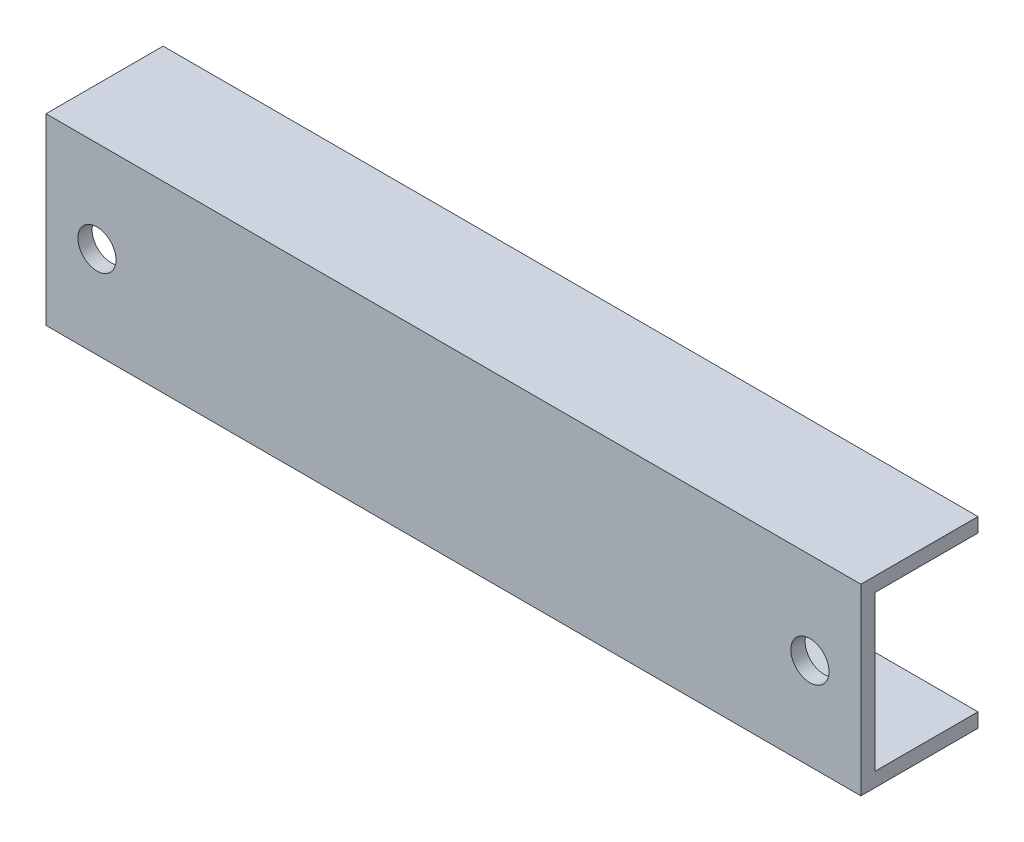
from build123d import *

# Parameters (mm, degrees)
BOSS_EXTRUDE1_DEPTH = 50.8
SKETCH3_R           = 2.38125
CUT_EXTRUDE1_DEPTH  = 15.605


with BuildPart() as part:
    # Sketch1 → Boss-Extrude1 (new body, symmetric)
    with BuildSketch(Plane(origin=(0, 0, 0), x_dir=(0, 0, -1), z_dir=(1, 0, 0))):
        Polygon((0, 11.43), (0, -11.43), (14.605, -11.43), (14.605, -9.652), (1.778, -9.652), (1.778, 9.652), (14.605, 9.652), (14.605, 11.43), align=None)
    extrude(amount=BOSS_EXTRUDE1_DEPTH, both=True)

    # Sketch3 → Cut-Extrude1 (cut, through all)
    with BuildSketch(Plane.XY):
        with Locations((44.45, 0)):
            Circle(SKETCH3_R)
    cut_extrude1 = extrude(amount=-CUT_EXTRUDE1_DEPTH, mode=Mode.SUBTRACT)

    # Mirror1: Cut-Extrude1 across plane
    add(cut_extrude1.mirror(Plane(origin=(0, 0, 0), x_dir=(0, 0, 1), z_dir=(1, 0, 0))), mode=Mode.SUBTRACT)


solid = part.part
